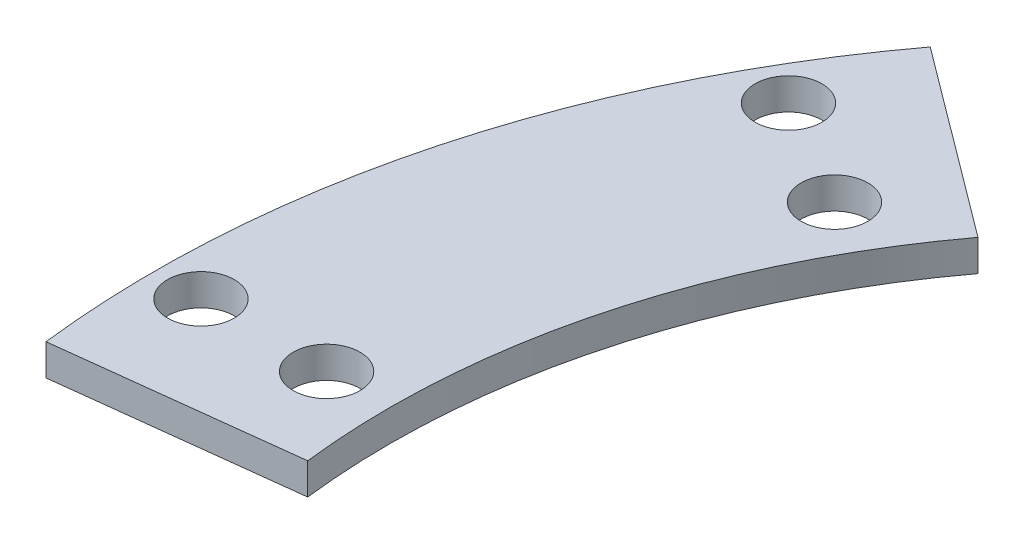
from build123d import *

# Parameters (mm, degrees)
SKETCH1_R           = 2.125
BOSS_EXTRUDE1_DEPTH = 2


with BuildPart() as part:
    # Sketch1 → Boss-Extrude1 (new body)
    with BuildSketch(Plane(origin=(0, 0, 0), x_dir=(1, 0, 0), z_dir=(0, 1, 0))):
        with BuildLine():
            Line((-37.655823606, 28.125414637), (-49.673639651, 37.101610798))
            ThreePointArc((-49.673639651, 37.101610798), (-59.88740123, 16.046780796), (-61.569439235, -7.294117647))
            Line((-61.569439235, -7.294117647), (-46.673607162, -5.529411765))
            ThreePointArc((-46.673607162, -5.529411765), (-45.398513836, 12.16449512), (-37.655823606, 28.125414637))
        make_face()
        with Locations((-44.167295593, 25.5)):
            Circle(SKETCH1_R, mode=Mode.SUBTRACT)
        with Locations((-51.095498823, 29.5)):
            Circle(SKETCH1_R, mode=Mode.SUBTRACT)
        with Locations((-59, 0)):
            Circle(SKETCH1_R, mode=Mode.SUBTRACT)
        with Locations((-51, 0)):
            Circle(SKETCH1_R, mode=Mode.SUBTRACT)
    extrude(amount=BOSS_EXTRUDE1_DEPTH)


solid = part.part
